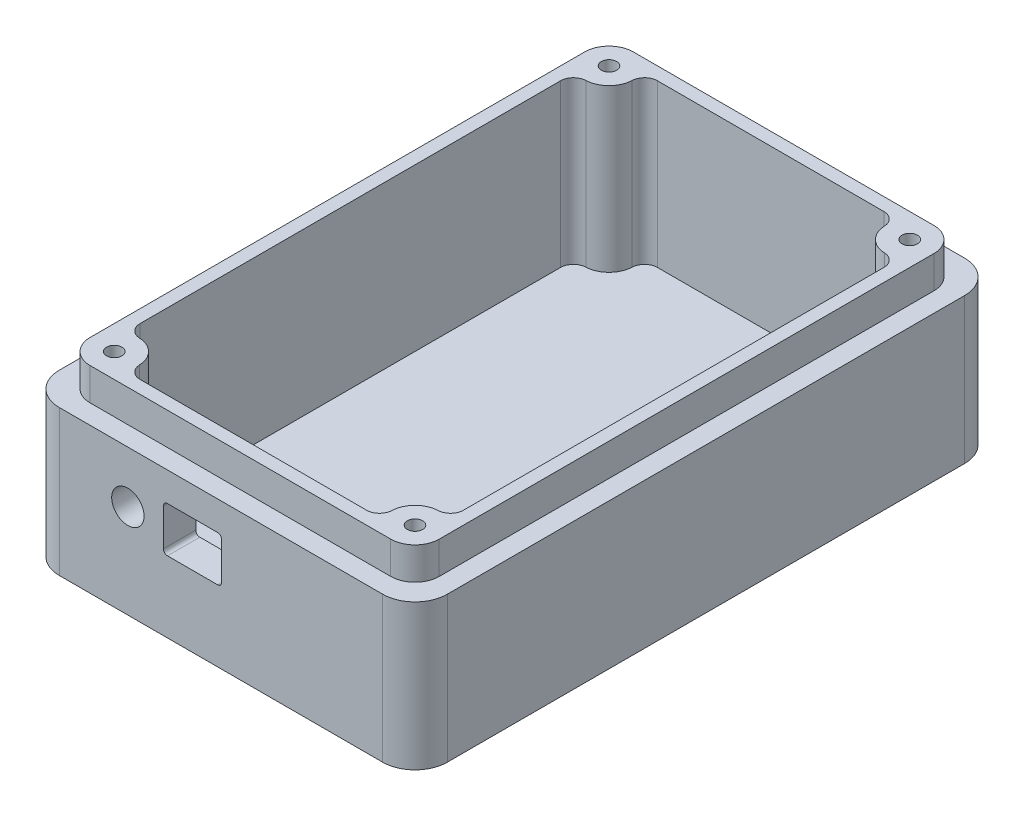
from build123d import *

# Parameters (mm, degrees)
SKETCH1_W           = 76.2
SKETCH1_H           = 114.3
BOSS_EXTRUDE1_DEPTH = 3.175
SKETCH3_W           = 76.2
SKETCH3_H           = 114.3
SKETCH3_W_2         = 63.5
SKETCH3_H_2         = 101.6
BOSS_EXTRUDE2_DEPTH = 25.4
CUT_EXTRUDE1_REACH  = 116.3
SKETCH4_R           = 3.175
SKETCH4_W           = 11.43
SKETCH4_H           = 8.89
SKETCH5_W           = 68.58
SKETCH5_H           = 106.68
SKETCH5_W_2         = 63.5
SKETCH5_H_2         = 101.6
BOSS_EXTRUDE3_DEPTH = 6.35
FILLET3_R           = 6.35
FILLET4_R           = 4.7625
FILLET5_R           = 3.175
FILLET6_R           = 0.79375
SKETCH6_R           = 4.7625
BOSS_EXTRUDE4_DEPTH = 31.75
SKETCH8_R           = 1.4986
CUT_EXTRUDE2_DEPTH  = 12.7
FILLET8_R           = 2.54


with BuildPart() as part:
    # Sketch1 → Boss-Extrude1 (new body)
    with BuildSketch(Plane(origin=(0, 0, 0), x_dir=(1, 0, 0), z_dir=(0, 1, 0))):
        Rectangle(SKETCH1_W, SKETCH1_H)
    extrude(amount=BOSS_EXTRUDE1_DEPTH)

    # Sketch3 → Boss-Extrude2 (add)
    with BuildSketch(Plane(origin=(0, 3.175, 0), x_dir=(1, 0, 0), z_dir=(0, 1, 0))):
        Rectangle(SKETCH3_W, SKETCH3_H)
        Rectangle(SKETCH3_W_2, SKETCH3_H_2, mode=Mode.SUBTRACT)
    extrude(amount=BOSS_EXTRUDE2_DEPTH)

    # Sketch4 → Cut-Extrude1 (cut, up to next)
    with BuildSketch(Plane.XY.offset(57.15), mode=Mode.PRIVATE) as cut_extrude1_sk1:
        with Locations((-18.288, 18.415)):
            Circle(SKETCH4_R)
    cut_extrude1_tool1 = extrude(cut_extrude1_sk1.sketch, amount=-CUT_EXTRUDE1_REACH, mode=Mode.PRIVATE) & part.part
    add(cut_extrude1_tool1.solids().sort_by_distance((-18.288, 18.415, 57.15))[0], mode=Mode.SUBTRACT)
    # Sketch4 → Cut-Extrude1 (cut, up to next)
    with BuildSketch(Plane.XY.offset(57.15), mode=Mode.PRIVATE) as cut_extrude1_sk2:
        with Locations((-5.588, 18.415)):
            Rectangle(SKETCH4_W, SKETCH4_H)
    cut_extrude1_tool2 = extrude(cut_extrude1_sk2.sketch, amount=-CUT_EXTRUDE1_REACH, mode=Mode.PRIVATE) & part.part
    add(cut_extrude1_tool2.solids().sort_by_distance((-5.588, 18.415, 57.15))[0], mode=Mode.SUBTRACT)

    # Sketch5 → Boss-Extrude3 (add)
    with BuildSketch(Plane(origin=(0, 28.575, 0), x_dir=(1, 0, 0), z_dir=(0, 1, 0))):
        Rectangle(SKETCH5_W, SKETCH5_H)
        Rectangle(SKETCH5_W_2, SKETCH5_H_2, mode=Mode.SUBTRACT)
    extrude(amount=BOSS_EXTRUDE3_DEPTH)

    # Fillet3
    fillet3_edges = [part.edges().sort_by_distance(p)[0] for p in [
        (38.1, 14.2875, 57.15),
        (-38.1, 14.2875, 57.15),
        (-38.1, 14.2875, -57.15),
        (38.1, 14.2875, -57.15),
    ]]
    fillet(fillet3_edges, radius=FILLET3_R)

    # Fillet4
    fillet4_edges = [part.edges().sort_by_distance(p)[0] for p in [
        (-34.29, 31.75, -53.34),
        (-34.29, 31.75, 53.34),
        (34.29, 31.75, 53.34),
        (34.29, 31.75, -53.34),
    ]]
    fillet(fillet4_edges, radius=FILLET4_R)

    # Fillet5
    fillet5_edges = [part.edges().sort_by_distance(p)[0] for p in [
        (-31.75, 19.05, 50.8),
        (31.75, 19.05, 50.8),
        (31.75, 19.05, -50.8),
        (-31.75, 19.05, -50.8),
    ]]
    fillet(fillet5_edges, radius=FILLET5_R)

    # Fillet6
    fillet6_edges = [part.edges().sort_by_distance(p)[0] for p in [
        (0.127, 22.86, 53.975),
        (0.127, 13.97, 53.975),
        (-11.303, 13.97, 53.975),
        (-11.303, 22.86, 53.975),
    ]]
    fillet(fillet6_edges, radius=FILLET6_R)

    # Sketch6 → Boss-Extrude4 (add)
    with BuildSketch(Plane(origin=(0, 3.175, 0), x_dir=(1, 0, 0), z_dir=(0, 1, 0))):
        with Locations((-29.5275, 48.5775)):
            Circle(SKETCH6_R)
        with Locations((29.5275, 48.5775)):
            Circle(SKETCH6_R)
        with Locations((29.5275, -48.5775)):
            Circle(SKETCH6_R)
        with Locations((-29.5275, -48.5775)):
            Circle(SKETCH6_R)
    extrude(amount=BOSS_EXTRUDE4_DEPTH)

    # Sketch8 → Cut-Extrude2 (cut)
    with BuildSketch(Plane(origin=(0, 34.925, 0), x_dir=(1, 0, 0), z_dir=(0, 1, 0))):
        with Locations((-29.5275, 48.5775)):
            Circle(SKETCH8_R)
        with Locations((29.5275, 48.5775)):
            Circle(SKETCH8_R)
        with Locations((29.5275, -48.5775)):
            Circle(SKETCH8_R)
        with Locations((-29.5275, -48.5775)):
            Circle(SKETCH8_R)
    extrude(amount=-CUT_EXTRUDE2_DEPTH, mode=Mode.SUBTRACT)

    # Fillet8
    fillet8_edges = [part.edges().sort_by_distance(p)[0] for p in [
        (-31.75, 19.05, -44.365386516),
        (-25.315386516, 19.05, -50.8),
        (25.315386516, 19.05, -50.8),
        (31.75, 19.05, -44.365386516),
        (31.75, 19.05, 44.365386516),
        (25.315386516, 19.05, 50.8),
        (-25.315386516, 19.05, 50.8),
        (-31.75, 19.05, 44.365386516),
    ]]
    fillet(fillet8_edges, radius=FILLET8_R)


solid = part.part
